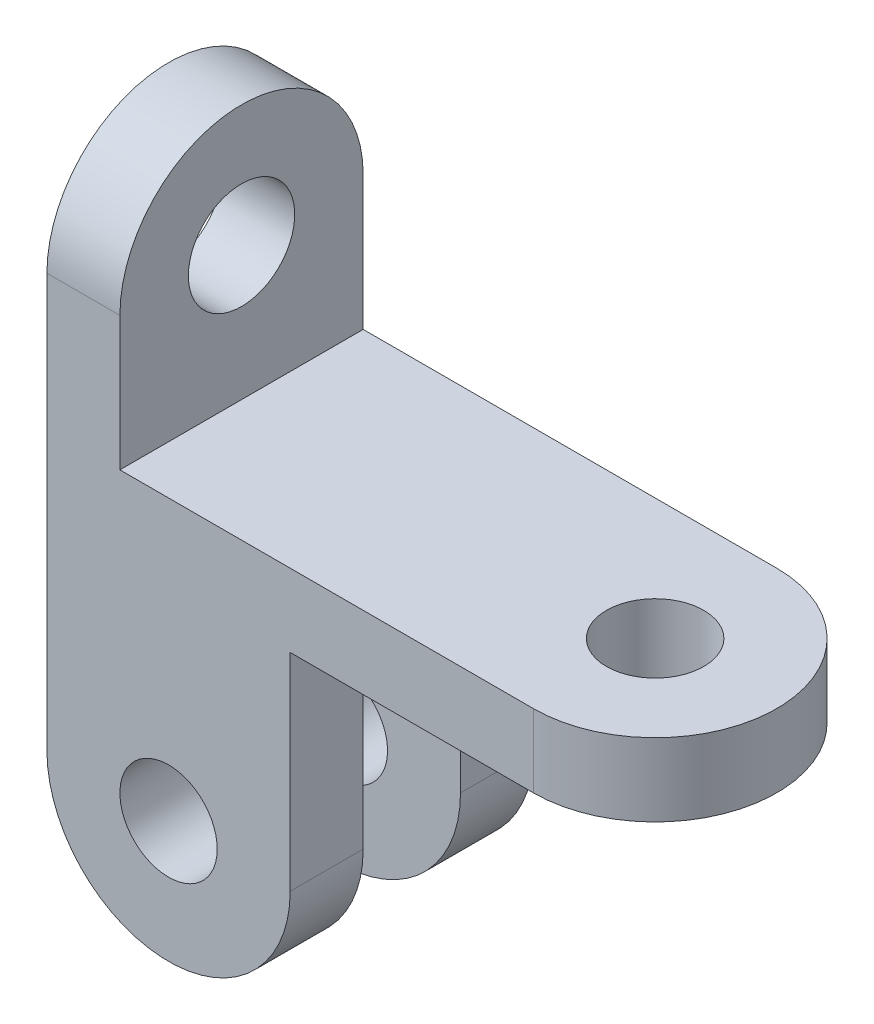
from build123d import *

# Parameters (mm, degrees)
SKETCH1_R           = 8
BOSS_EXTRUDE2_DEPTH = 12
SKETCH3_R           = 8.742551749
BOSS_EXTRUDE3_DEPTH = 12
SKETCH4_R           = 8
BOSS_EXTRUDE4_DEPTH = 12
SKETCH5_R           = 8
BOSS_EXTRUDE5_DEPTH = 12


with BuildPart() as part:
    # Sketch1 → Boss-Extrude2 (new body)
    with BuildSketch(Plane(origin=(0, 0, 0), x_dir=(1, 0, 0), z_dir=(0, 1, 0))):
        with BuildLine():
            Line((-64.715447154, 17.804878049), (15.284552846, 17.804878049))
            ThreePointArc((15.284552846, 17.804878049), (35.284552846, -2.195121951), (15.284552846, -22.195121951))
            Line((15.284552846, -22.195121951), (-64.715447154, -22.195121951))
            Line((-64.715447154, -22.195121951), (-64.715447154, 17.804878049))
        make_face()
        with Locations((15.284552846, -2.195121951)):
            Circle(SKETCH1_R, mode=Mode.SUBTRACT)
    extrude(amount=BOSS_EXTRUDE2_DEPTH)

    # Sketch3 → Boss-Extrude3 (add)
    with BuildSketch(Plane.ZY.offset(64.715447154)):
        with BuildLine():
            ThreePointArc((22.195121951, 34), (2.195121951, 54), (-17.804878049, 34))
            Line((-17.804878049, 34), (-17.804878049, 12))
            Line((-17.804878049, 12), (22.195121951, 12))
            Line((22.195121951, 12), (22.195121951, 34))
        make_face()
        with Locations((2.195121951, 34)):
            Circle(SKETCH3_R, mode=Mode.SUBTRACT)
    extrude(amount=-BOSS_EXTRUDE3_DEPTH)

    # Sketch4 → Boss-Extrude4 (add)
    with BuildSketch(Plane(origin=(0, 0, -17.804878049), x_dir=(-1, 0, 0), z_dir=(0, 0, -1))):
        with BuildLine():
            Line((64.715447154, 0), (64.715447154, -34))
            ThreePointArc((64.715447154, -34), (44.715447154, -54), (24.715447154, -34))
            Line((24.715447154, -34), (24.715447154, 0))
            Line((24.715447154, 0), (64.715447154, 0))
        make_face()
        with Locations((44.715447154, -34)):
            Circle(SKETCH4_R, mode=Mode.SUBTRACT)
    extrude(amount=-BOSS_EXTRUDE4_DEPTH)

    # Sketch5 → Boss-Extrude5 (add)
    with BuildSketch(Plane.XY.offset(22.195121951)):
        with BuildLine():
            Line((-64.715447154, 0), (-64.715447154, -34))
            ThreePointArc((-64.715447154, -34), (-44.715447154, -54), (-24.715447154, -34))
            Line((-24.715447154, -34), (-24.715447154, 0))
            Line((-24.715447154, 0), (-64.715447154, 0))
        make_face()
        with Locations((-44.715447154, -34)):
            Circle(SKETCH5_R, mode=Mode.SUBTRACT)
    extrude(amount=-BOSS_EXTRUDE5_DEPTH)


solid = part.part
